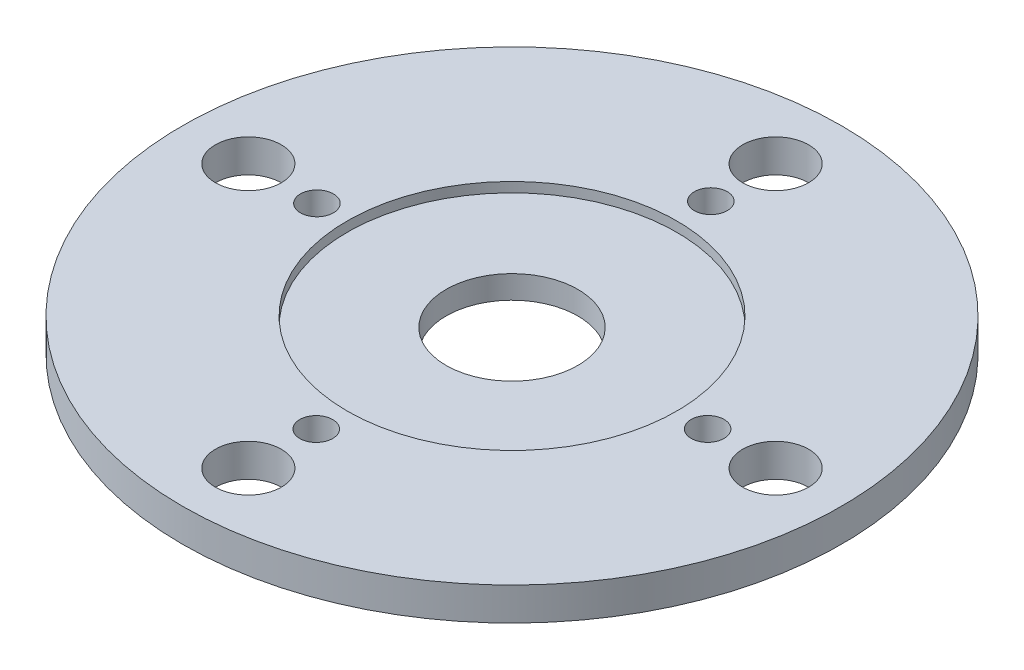
from build123d import *

# Parameters (mm, degrees)
SKETCH1_R           = 10
SKETCH1_R_2         = 2
SKETCH1_R_3         = 1
SKETCH1_R_4         = 0.5
BOSS_EXTRUDE1_DEPTH = 1
SKETCH2_R           = 5
CUT_EXTRUDE1_DEPTH  = 0.3


with BuildPart() as part:
    # Sketch1 → Boss-Extrude1 (new body)
    with BuildSketch(Plane(origin=(0, 0, 0), x_dir=(1, 0, 0), z_dir=(0, 1, 0))):
        with Locations(Location((0, 0, 0), (0, 0, 270))):  # turned: the seam where the file's is
            Circle(SKETCH1_R)
        with Locations(Location((0, 0, 0), (0, 0, 270))):  # turned: the seam where the file's is
            Circle(SKETCH1_R_2, mode=Mode.SUBTRACT)
        with Locations(Location((-8, 0, 0), (0, 0, 270))):  # turned: the seam where the file's is
            Circle(SKETCH1_R_3, mode=Mode.SUBTRACT)
        with Locations(Location((-5.919172613, 0, 0), (0, 0, 270))):  # turned: the seam where the file's is
            Circle(SKETCH1_R_4, mode=Mode.SUBTRACT)
        with Locations(Location((0, -5.941415712, 0), (0, 0, 90))):  # turned: the seam where the file's is
            Circle(SKETCH1_R_4, mode=Mode.SUBTRACT)
        with Locations(Location((0, -8, 0), (0, 0, 90))):  # turned: the seam where the file's is
            Circle(SKETCH1_R_3, mode=Mode.SUBTRACT)
        with Locations(Location((5.936823246, 0, 0), (0, 0, 90))):  # turned: the seam where the file's is
            Circle(SKETCH1_R_4, mode=Mode.SUBTRACT)
        with Locations(Location((8, 0, 0), (0, 0, 90))):  # turned: the seam where the file's is
            Circle(SKETCH1_R_3, mode=Mode.SUBTRACT)
        with Locations(Location((0, 6.0333524, 0), (0, 0, 270))):  # turned: the seam where the file's is
            Circle(SKETCH1_R_4, mode=Mode.SUBTRACT)
        with Locations(Location((0, 8, 0), (0, 0, 270))):  # turned: the seam where the file's is
            Circle(SKETCH1_R_3, mode=Mode.SUBTRACT)
    extrude(amount=BOSS_EXTRUDE1_DEPTH)

    # Sketch2 → Cut-Extrude1 (cut)
    with BuildSketch(Plane(origin=(0, 1, 0), x_dir=(1, 0, 0), z_dir=(0, 1, 0))):
        with Locations(Location((0, 0, 0), (0, 0, 270))):  # turned: the seam where the file's is
            Circle(SKETCH2_R)
    extrude(amount=-CUT_EXTRUDE1_DEPTH, mode=Mode.SUBTRACT)


solid = part.part
